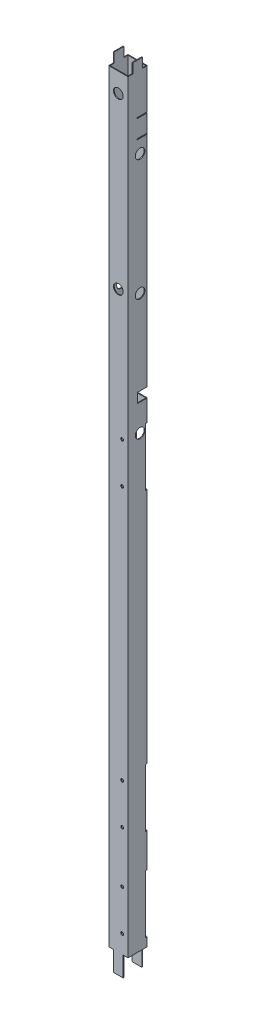
from build123d import *

# Parameters (mm, degrees)
SKETCH1_W           = 37
SKETCH1_H           = 37
BOSS_EXTRUDE1_DEPTH = 1637.5
SKETCH2_W           = 10
SKETCH2_H           = 20
CUT_EXTRUDE1_DEPTH  = 40
SKETCH3_W           = 21
SKETCH3_H           = 2
CUT_EXTRUDE2_DEPTH  = 20
SKETCH4_W           = 10
SKETCH4_H           = 41
CUT_EXTRUDE3_DEPTH  = 1639.476807892
CUT_EXTRUDE4_DEPTH  = 20
SKETCH7_W           = 20
SKETCH7_H           = 20
CUT_EXTRUDE6_DEPTH  = 20
SKETCH8_W           = 4
SKETCH8_H           = 120
CUT_EXTRUDE7_DEPTH  = 22
SKETCH9_R           = 3
CUT_EXTRUDE8_DEPTH  = 22
LPATTERN1_COUNT     = 2
LPATTERN1_PITCH     = 190
LPATTERN2_COUNT     = 2
LPATTERN2_PITCH     = 800
SKETCH10_R          = 10
CUT_EXTRUDE9_DEPTH  = 1639.476807892
SKETCH11_R          = 10
CUT_EXTRUDE10_DEPTH = 1639.476807892


with BuildPart() as part:
    # Sketch1 → Boss-Extrude1 (new body)
    with BuildSketch(Plane(origin=(0, 0, 0), x_dir=(1, 0, 0), z_dir=(0, 1, 0))):
        with BuildLine():
            Line((0.5, 0), (39.5, 0))
            ThreePointArc((39.5, 0), (39.853553391, 0.146446609), (40, 0.5))
            Line((40, 0.5), (40, 39.5))
            ThreePointArc((40, 39.5), (39.853553391, 39.853553391), (39.5, 40))
            Line((39.5, 40), (0.5, 40))
            ThreePointArc((0.5, 40), (0.146446609, 39.853553391), (0, 39.5))
            Line((0, 39.5), (0, 0.5))
            ThreePointArc((0, 0.5), (0.146446609, 0.146446609), (0.5, 0))
        make_face()
        with Locations((20, 20)):
            Rectangle(SKETCH1_W, SKETCH1_H, mode=Mode.SUBTRACT)
    extrude(amount=BOSS_EXTRUDE1_DEPTH)

    # Sketch2 → Cut-Extrude1 (cut)
    with BuildSketch(Plane(origin=(40, 0, 0), x_dir=(0, 0, -1), z_dir=(1, 0, 0))):
        with Locations((35, 1627.5)):
            Rectangle(SKETCH2_W, SKETCH2_H)
        with Locations((5, 1627.5)):
            Rectangle(SKETCH2_W, SKETCH2_H)
    extrude(amount=-CUT_EXTRUDE1_DEPTH, mode=Mode.SUBTRACT)

    # Sketch3 → Cut-Extrude2 (cut)
    with BuildSketch(Plane(origin=(40, 0, 0), x_dir=(0, 0, -1), z_dir=(1, 0, 0))):
        with Locations((29.5, 1534)):
            Rectangle(SKETCH3_W, SKETCH3_H)
        with Locations((29.5, 1496)):
            Rectangle(SKETCH3_W, SKETCH3_H)
    extrude(amount=-CUT_EXTRUDE2_DEPTH, mode=Mode.SUBTRACT)

    # Sketch4 → Cut-Extrude3 (cut, through all)
    with BuildSketch(Plane.XY):
        with Locations((35, 20.5)):
            Rectangle(SKETCH4_W, SKETCH4_H)
        with Locations((5, 20.5)):
            Rectangle(SKETCH4_W, SKETCH4_H)
    extrude(amount=-CUT_EXTRUDE3_DEPTH, mode=Mode.SUBTRACT)

    # Sketch5 → Cut-Extrude4 (cut)
    with BuildSketch(Plane(origin=(40, 0, -40), x_dir=(1, 0, 0), z_dir=(0, 0, 1))):
        Polygon((-40, 190.5), (-20, 190.5), (-20, 231), (-30, 231), (-30, 211), (-40, 211), align=None)
        Polygon((-40, 380.5), (-20, 380.5), (-20, 421), (-30, 421), (-30, 401), (-40, 401), align=None)
        Polygon((-40, 570.5), (-20, 570.5), (-20, 611), (-30, 611), (-30, 591), (-40, 591), align=None)
        Polygon((-40, 760.5), (-20, 760.5), (-20, 801), (-30, 801), (-30, 781), (-40, 781), align=None)
    extrude(amount=CUT_EXTRUDE4_DEPTH, mode=Mode.SUBTRACT)

    # Sketch7 → Cut-Extrude6 (cut)
    with BuildSketch(Plane(origin=(40, 0, 0), x_dir=(0, 0, -1), z_dir=(1, 0, 0))):
        with Locations((30, 1033)):
            Rectangle(SKETCH7_W, SKETCH7_H)
    extrude(amount=-CUT_EXTRUDE6_DEPTH, mode=Mode.SUBTRACT)

    # Sketch8 → Cut-Extrude7 (cut)
    with BuildSketch(Plane(origin=(40, 0, 0), x_dir=(0, 0, -1), z_dir=(1, 0, 0))):
        with Locations((38, 119)):
            Rectangle(SKETCH8_W, SKETCH8_H)
    cut_extrude7 = extrude(amount=-CUT_EXTRUDE7_DEPTH, mode=Mode.SUBTRACT)

    # Sketch9 → Cut-Extrude8 (cut)
    with BuildSketch(Plane(origin=(0, 0, -1.5), x_dir=(-1, 0, 0), z_dir=(0, 0, -1))):
        with Locations((-28, 162.5)):
            Circle(SKETCH9_R)
        with Locations((-28, 78.5)):
            Circle(SKETCH9_R)
    cut_extrude8 = extrude(amount=-CUT_EXTRUDE8_DEPTH, mode=Mode.SUBTRACT)

    # LPattern1: Cut-Extrude7, Cut-Extrude8 ×2
    with Locations(*[(0, i * LPATTERN1_PITCH, 0) for i in range(1, LPATTERN1_COUNT)]):
        add(cut_extrude7, mode=Mode.SUBTRACT)
        add(cut_extrude8, mode=Mode.SUBTRACT)

    # LPattern2: Cut-Extrude7, Cut-Extrude8 ×2
    with Locations(*[(0, i * LPATTERN2_PITCH, 0) for i in range(1, LPATTERN2_COUNT)]):
        add(cut_extrude7, mode=Mode.SUBTRACT)
        add(cut_extrude8, mode=Mode.SUBTRACT)

    # Sketch10 → Cut-Extrude9 (cut, through all)
    with BuildSketch(Plane.XY):
        with Locations((20, 1577.5)):
            Circle(SKETCH10_R)
        with Locations((20, 1227.5)):
            Circle(SKETCH10_R)
    extrude(amount=-CUT_EXTRUDE9_DEPTH, mode=Mode.SUBTRACT)

    # Sketch11 → Cut-Extrude10 (cut, through all)
    with BuildSketch(Plane.ZY):
        with Locations((-25, 1467.5)):
            Circle(SKETCH11_R)
        with Locations((-25, 1217.5)):
            Circle(SKETCH11_R)
        with Locations((-25, 967.5)):
            Circle(SKETCH11_R)
    extrude(amount=-CUT_EXTRUDE10_DEPTH, mode=Mode.SUBTRACT)


solid = part.part
